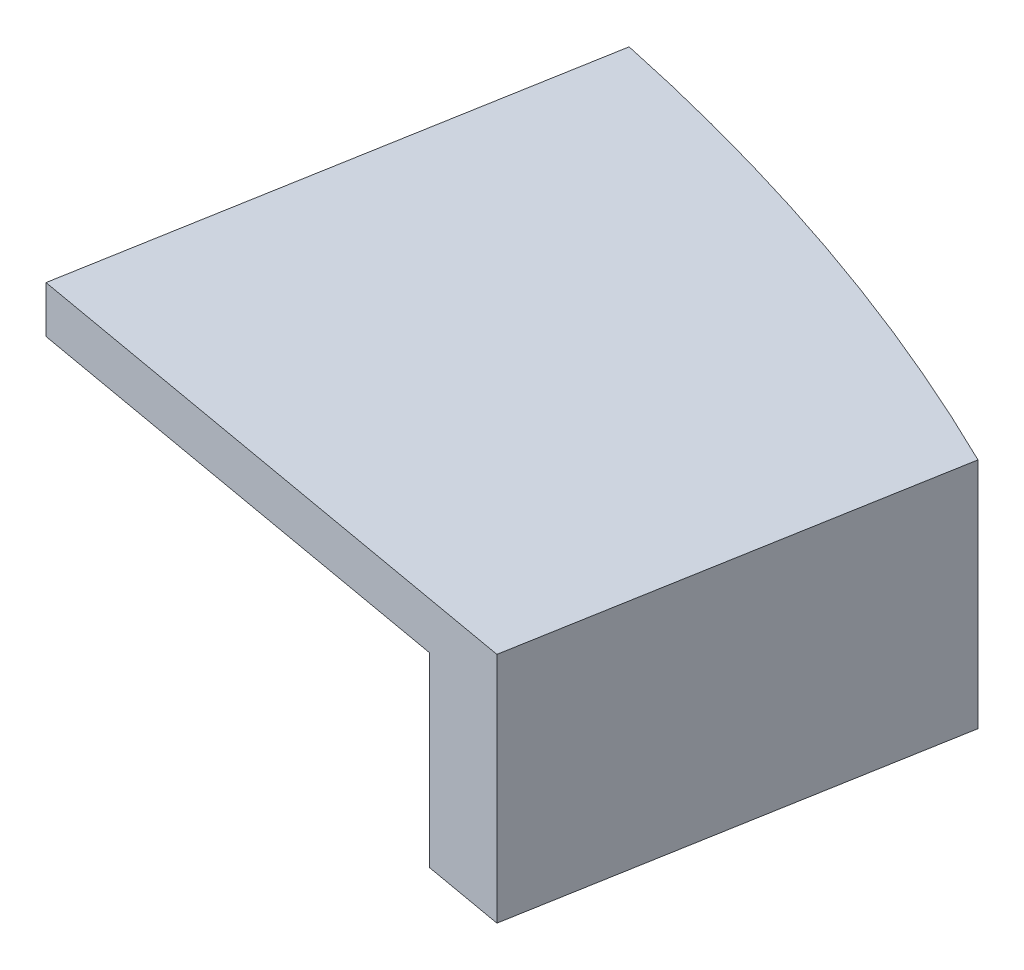
from build123d import *

# Parameters (mm, degrees)
BOSS_EXTRUDE7_DEPTH = 1.68
BOSS_EXTRUDE8_DEPTH = 6.695435


with BuildPart() as part:
    # Sketch23 → Boss-Extrude7 (new body)
    with BuildSketch(Plane(origin=(0, 12.527717687, 0), x_dir=(1, 0, 0), z_dir=(0, 1, 0))):
        with BuildLine():
            Line((17.863123843, 63.129446847), (14.718163043, 45.293487391))
            Line((14.718163043, 45.293487391), (34.414318061, 41.820523845))
            Line((34.414318061, 41.820523845), (37.008919102, 56.535237557))
            add(Edge.make_bspline(
                [(37.008919102, 56.535237557), (27.963542945, 60.982758463), (17.863123843, 63.129446847)],
                knots=[4.196334531, 4.196334531, 4.196334531, 4.471902655, 4.471902655, 4.471902655], degree=2, weights=[1, 0.990522784, 1]))
        make_face()
    extrude(amount=-BOSS_EXTRUDE7_DEPTH)

    # Sketch24 → Boss-Extrude8 (add)
    with BuildSketch(Plane.XZ.offset(-10.847717687)):
        with BuildLine():
            Line((16.906130039, -57.702065086), (33.647861841, -54.750046066))
            Line((33.647861841, -54.750046066), (31.459894802, -42.341468378))
            Line((31.459894802, -42.341468378), (34.414318061, -41.820523845))
            Line((34.414318061, -41.820523845), (37.008919102, -56.535237557))
            add(Edge.make_bspline(
                [(17.863123843, -63.129446847), (27.963542945, -60.982758463), (37.008919102, -56.535237557)],
                knots=[1.811282652, 1.811282652, 1.811282652, 2.086850776, 2.086850776, 2.086850776], degree=2, weights=[1, 0.990522784, 1]))
            Line((17.863123843, -63.129446847), (16.906130039, -57.702065086))
        make_face()
    extrude(amount=BOSS_EXTRUDE8_DEPTH)


solid = part.part
